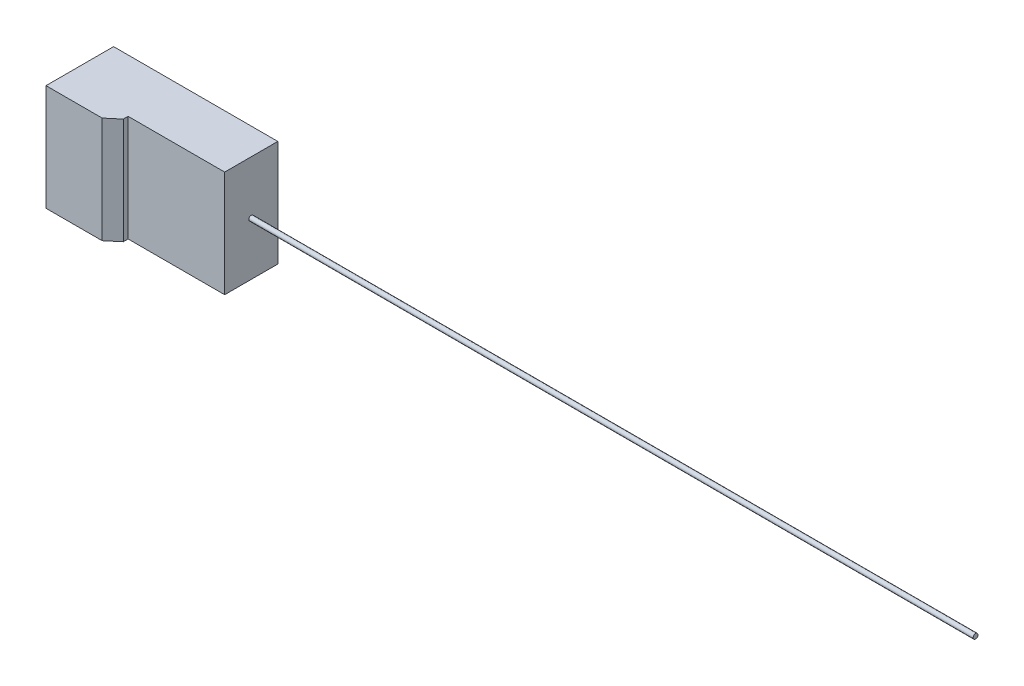
from build123d import *

# Parameters (mm, degrees)
CROQUIS1_W              = 34
CROQUIS1_H              = 22
SALIENTE_EXTRUIR1_DEPTH = 11
CROQUIS2_W              = 14
CROQUIS2_H              = 22
SALIENTE_EXTRUIR2_DEPTH = 3
CHAFL_N1_SIZE           = 2
CHAFL_N1_SIZE2          = 2.383507185
CROQUIS3_R              = 0.5
SALIENTE_EXTRUIR3_DEPTH = 150


with BuildPart() as part:
    # Croquis1 → Saliente-Extruir1 (new body)
    with BuildSketch(Plane.XY):
        Rectangle(CROQUIS1_W, CROQUIS1_H)
    extrude(amount=SALIENTE_EXTRUIR1_DEPTH)

    # Croquis2 → Saliente-Extruir2 (add)
    with BuildSketch(Plane.XY.offset(11)):
        with Locations((-10, 0)):
            Rectangle(CROQUIS2_W, CROQUIS2_H)
    extrude(amount=SALIENTE_EXTRUIR2_DEPTH)

    # Chaflán1
    chafl_n1_edges = [part.edges().sort_by_distance(p)[0] for p in [
        (-3, 0, 14),
    ]]
    chafl_n1_side = [part.faces().sort_by_distance(p)[0] for p in [
        (-3, 0, 12.5),
    ]]
    chamfer(chafl_n1_edges, length=CHAFL_N1_SIZE, length2=CHAFL_N1_SIZE2, reference=chafl_n1_side[0])

    # Croquis3 → Saliente-Extruir3 (add)
    with BuildSketch(Plane(origin=(17, 0, 0), x_dir=(0, 0, -1), z_dir=(1, 0, 0))):
        with Locations((-5.5, 0)):
            Circle(CROQUIS3_R)
    extrude(amount=SALIENTE_EXTRUIR3_DEPTH)


solid = part.part
